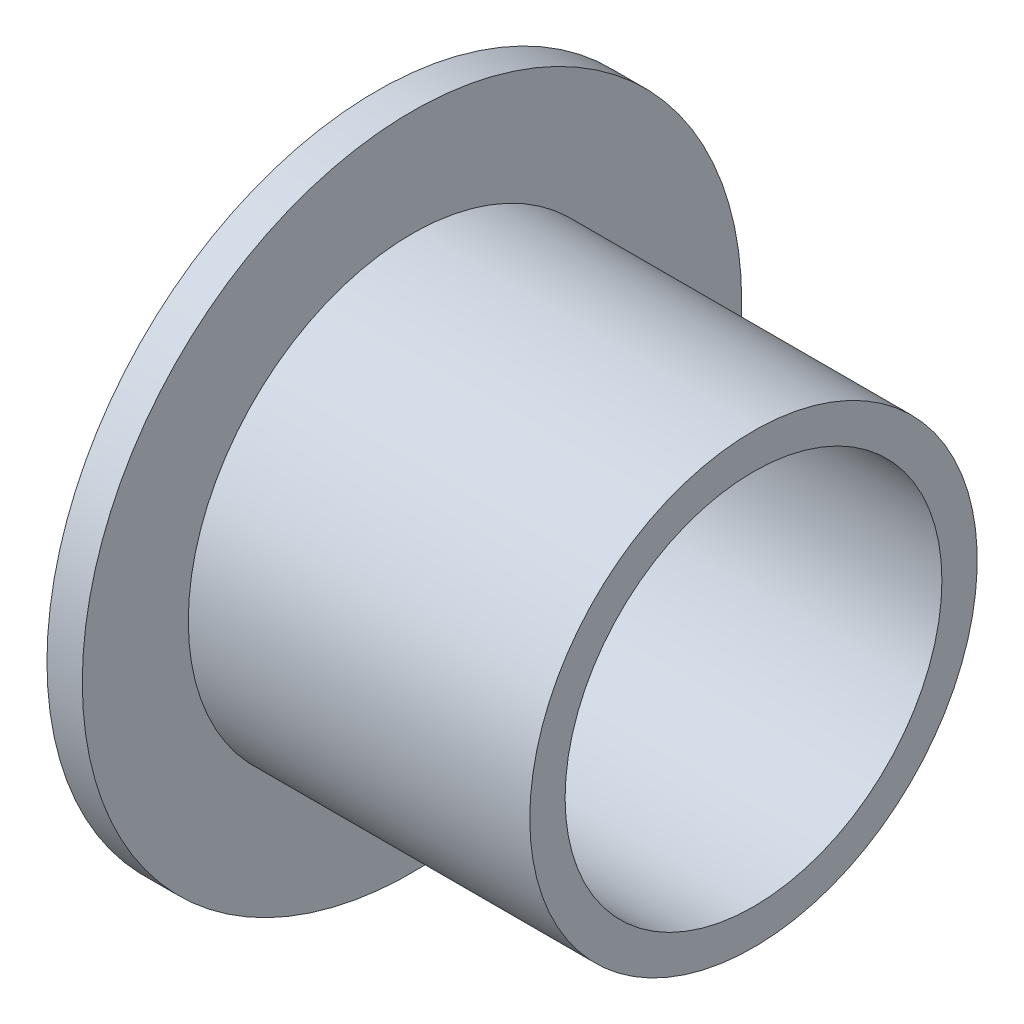
from build123d import *


with BuildPart() as part:
    # Sketch2 → Revolve1 (revolve)
    with BuildSketch(Plane.XY, mode=Mode.PRIVATE) as revolve1_sk:
        Polygon((-1.190625, 11.1125), (-1.190625, 6.35), (11.509375, 6.35), (11.509375, 7.540625), (0, 7.540625), (0, 11.1125), align=None)
    revolve(revolve1_sk.sketch.rotate(Axis((0, 0, 0), (1, 0, 0)), 90), axis=Axis((0, 0, 0), (1, 0, 0)))  # turned: the seam where the file's is


solid = part.part
